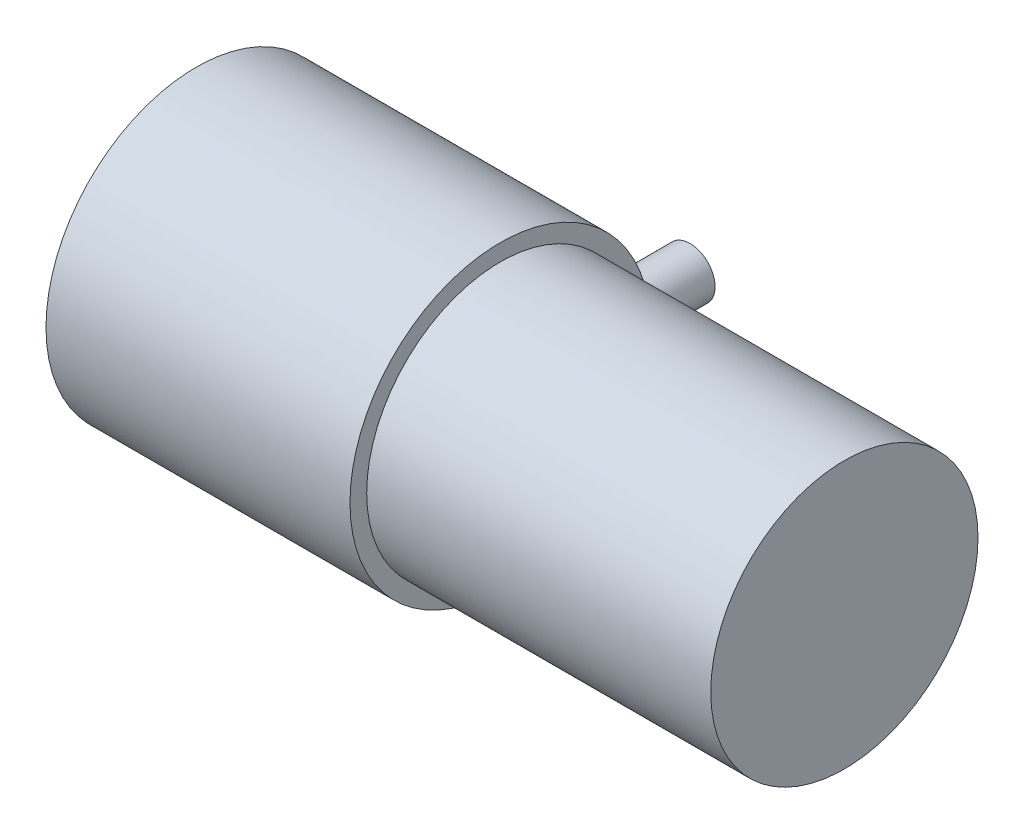
from build123d import *

# Parameters (mm, degrees)
SKETCH_1_R      = 13.5
EXTRUDE_1_DEPTH = 27.3
SKETCH_2_R      = 12
EXTRUDE_2_DEPTH = 30.9
SKETCH_3_R      = 2.05
EXTRUDE_3_DEPTH = 6.2
SKETCH_4_R      = 2.25
EXTRUDE_4_DEPTH = 6.2


with BuildPart() as part:
    # 草图1 → 凸台-拉伸1 (new body)
    with BuildSketch(Plane(origin=(0, 0, 0), x_dir=(0, 0, -1), z_dir=(1, 0, 0))):
        Circle(SKETCH_1_R)
    extrude(amount=EXTRUDE_1_DEPTH)

    # 草图2 → 凸台-拉伸2 (add)
    with BuildSketch(Plane(origin=(27.3, 0, 0), x_dir=(0, 0, -1), z_dir=(1, 0, 0))):
        Circle(SKETCH_2_R)
    extrude(amount=EXTRUDE_2_DEPTH)

    # 草图3 → 凸台-拉伸3 (add)
    with BuildSketch(Plane.ZY):
        Circle(SKETCH_3_R)
    extrude(amount=EXTRUDE_3_DEPTH)


with BuildPart() as body_2:
    # 草图4 → 凸台-拉伸4 (new body)
    with BuildSketch(Plane(origin=(0, 0, -13.5), x_dir=(-1, 0, 0), z_dir=(0, 0, -1))):
        with Locations((-24.6389246, 0)):
            Circle(SKETCH_4_R)
    extrude(amount=EXTRUDE_4_DEPTH)


solid = Compound([part.part, body_2.part])
